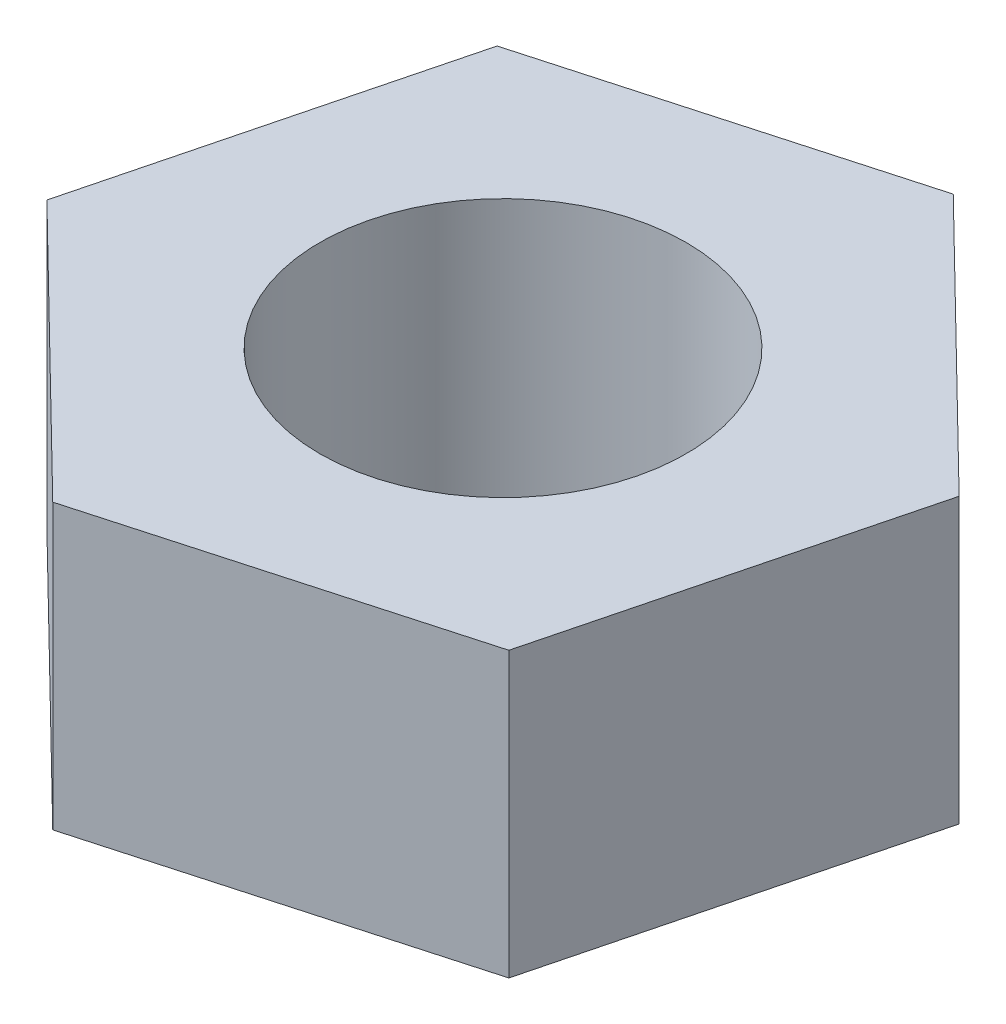
from build123d import *

# Parameters (mm, degrees)
SKETCH_1_R      = 2
EXTRUDE_1_DEPTH = 3.1


with BuildPart() as part:
    # 草图1 → 凸台-拉伸1 (new body)
    with BuildSketch(Plane(origin=(0, 0, 0), x_dir=(1, 0, 0), z_dir=(0, 1, 0))):
        Polygon((2.88966505, -2.825450271), (3.891744237, 1.089798206), (1.002079187, 3.915248477), (-2.88966505, 2.825450271), (-3.891744237, -1.089798206), (-1.002079187, -3.915248477), align=None)
        Circle(SKETCH_1_R, mode=Mode.SUBTRACT)
    extrude(amount=EXTRUDE_1_DEPTH)


solid = part.part
